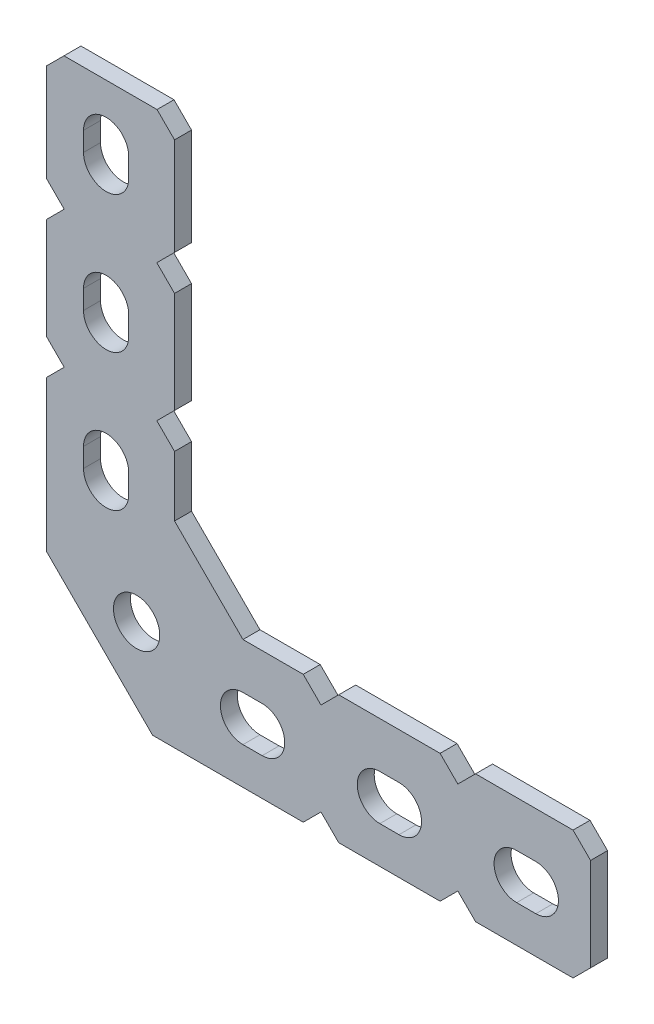
from build123d import *

# Parameters (mm, degrees)
SKETCH1_R           = 2.1463
BOSS_EXTRUDE1_DEPTH = 1.5748


with BuildPart() as part:
    # Sketch1 → Boss-Extrude1 (new body)
    with BuildSketch(Plane.XY.offset(1.5748)):
        Polygon((6.35, 34.284985055), (6.35, 43.3324), (4.7244, 44.958), (-3.9116, 44.958), (-5.5372, 43.3324), (-5.5372, 34.284985055), (-3.891214945, 32.639), (-5.5372, 30.993014945), (-5.5372, 21.584985055), (-3.891214945, 19.939), (-5.5372, 18.293014945), (-5.5372, 4.313373781), (4.313373781, -5.5372), (18.293014945, -5.5372), (19.939, -3.891214945), (21.584985055, -5.5372), (30.993014945, -5.5372), (32.639, -3.891214945), (34.284985055, -5.5372), (43.3324, -5.5372), (44.958, -3.9116), (44.958, 4.7244), (43.3324, 6.35), (34.284985055, 6.35), (32.639, 4.704014945), (30.993014945, 6.35), (21.584985055, 6.35), (19.939, 4.704014945), (18.293014945, 6.35), (12.7, 6.35), (6.35, 12.7), (6.35, 18.293014945), (4.704014945, 19.939), (6.35, 21.584985055), (6.35, 30.993014945), (4.704014945, 32.639), align=None)
        with Locations((2.828780678, 2.828780678)):
            Circle(SKETCH1_R, mode=Mode.SUBTRACT)
        with BuildLine():
            Line((12.7, 2.0955), (14.478, 2.0955))
            ThreePointArc((14.478, 2.0955), (16.5735, 0), (14.478, -2.0955))
            Line((14.478, -2.0955), (12.7, -2.0955))
            ThreePointArc((12.7, -2.0955), (10.6045, 0), (12.7, 2.0955))
        make_face(mode=Mode.SUBTRACT)
        with BuildLine():
            Line((-2.0955, 38.1), (-2.0955, 39.878))
            ThreePointArc((-2.0955, 39.878), (0, 41.9735), (2.0955, 39.878))
            Line((2.0955, 39.878), (2.0955, 38.1))
            ThreePointArc((2.0955, 38.1), (0, 36.0045), (-2.0955, 38.1))
        make_face(mode=Mode.SUBTRACT)
        with BuildLine():
            Line((-2.0955, 12.7), (-2.0955, 14.478))
            ThreePointArc((-2.0955, 14.478), (0, 16.5735), (2.0955, 14.478))
            Line((2.0955, 14.478), (2.0955, 12.7))
            ThreePointArc((2.0955, 12.7), (0, 10.6045), (-2.0955, 12.7))
        make_face(mode=Mode.SUBTRACT)
        with BuildLine():
            Line((-2.0955, 25.4), (-2.0955, 27.178))
            ThreePointArc((-2.0955, 27.178), (0, 29.2735), (2.0955, 27.178))
            Line((2.0955, 27.178), (2.0955, 25.4))
            ThreePointArc((2.0955, 25.4), (0, 23.3045), (-2.0955, 25.4))
        make_face(mode=Mode.SUBTRACT)
        with BuildLine():
            Line((25.4, 2.0955), (27.178, 2.0955))
            ThreePointArc((27.178, 2.0955), (29.2735, 0), (27.178, -2.0955))
            Line((27.178, -2.0955), (25.4, -2.0955))
            ThreePointArc((25.4, -2.0955), (23.3045, 0), (25.4, 2.0955))
        make_face(mode=Mode.SUBTRACT)
        with BuildLine():
            Line((38.1, 2.0955), (39.878, 2.0955))
            ThreePointArc((39.878, 2.0955), (41.9735, 0), (39.878, -2.0955))
            Line((39.878, -2.0955), (38.1, -2.0955))
            ThreePointArc((38.1, -2.0955), (36.0045, 0), (38.1, 2.0955))
        make_face(mode=Mode.SUBTRACT)
    extrude(amount=-BOSS_EXTRUDE1_DEPTH)


solid = part.part
